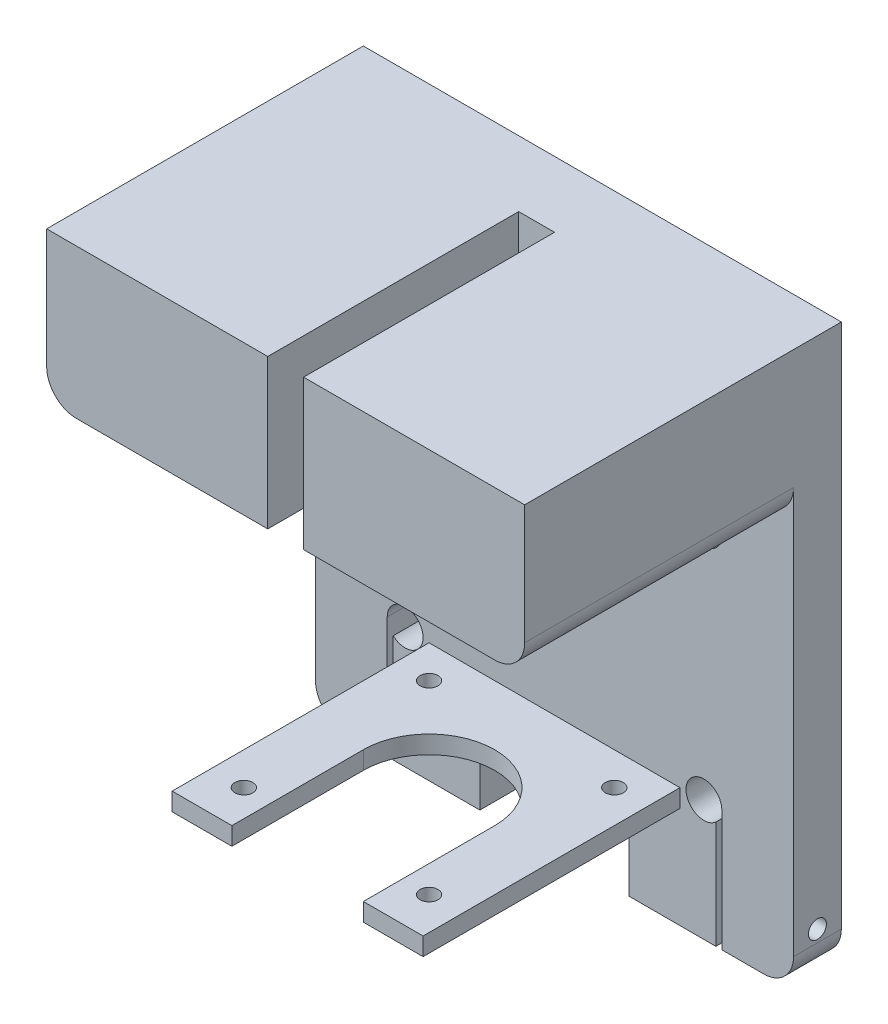
from build123d import *

# Parameters (mm, degrees)
EXTRUDE_1_DEPTH          = 8
SKETCH_3_W               = 42
SKETCH_3_H               = 3
EXTRUDE_2_DEPTH          = 43
CUT_EXTRUDE_1_REACH      = 78
SKETCH_4_R               = 1.5
SKETCH_5_W               = 25
SKETCH_5_H               = 17
CUT_EXTRUDE_2_DEPTH      = 9
SKETCH_7_R               = 3
CUT_EXTRUDE_3_DEPTH      = 9
FILLET_1_R               = 5
CUT_EXTRUDE_4_DEPTH      = 9
SKETCH_9_R               = 1.5
CUT_EXTRUDE_5_DEPTH      = 1
CUT_EXTRUDE_5_DEPTH_BACK = 81
SKETCH_12_W              = 80
SKETCH_12_H              = 25
EXTRUDE_4_DEPTH          = 45
SKETCH_13_W              = 6
SKETCH_13_H              = 25
CUT_EXTRUDE_6_DEPTH      = 42
FILLET_3_R               = 5
FILLET_4_R               = 5


with BuildPart() as part:
    # 草图1 → 凸台-拉伸1 (new body)
    with BuildSketch(Plane.XY):
        Polygon((-40, -42.5), (40, -42.5), (40, 42.5), (40, 50.5), (-40, 50.5), (-40, 42.5), align=None)
    extrude(amount=EXTRUDE_1_DEPTH)

    # 草图3 → 凸台-拉伸2 (add)
    with BuildSketch(Plane.XY.offset(8)):
        with Locations((0, -24)):
            Rectangle(SKETCH_3_W, SKETCH_3_H)
    extrude(amount=EXTRUDE_2_DEPTH)

    # 草图4 → 切除-拉伸1 (cut, up to next)
    with BuildSketch(Plane.XZ.offset(25.5), mode=Mode.PRIVATE) as cut_extrude_1_sk1:
        with Locations((-15.5, 44.5)):
            Circle(SKETCH_4_R)
    cut_extrude_1_tool1 = extrude(cut_extrude_1_sk1.sketch, amount=-CUT_EXTRUDE_1_REACH, mode=Mode.PRIVATE) & part.part
    add(cut_extrude_1_tool1.solids().sort_by_distance((-15.5, -25.5, 44.5))[0], mode=Mode.SUBTRACT)
    # 草图4 → 切除-拉伸1 (cut, up to next)
    with BuildSketch(Plane.XZ.offset(25.5), mode=Mode.PRIVATE) as cut_extrude_1_sk2:
        with Locations((15.5, 44.5)):
            Circle(SKETCH_4_R)
    cut_extrude_1_tool2 = extrude(cut_extrude_1_sk2.sketch, amount=-CUT_EXTRUDE_1_REACH, mode=Mode.PRIVATE) & part.part
    add(cut_extrude_1_tool2.solids().sort_by_distance((15.5, -25.5, 44.5))[0], mode=Mode.SUBTRACT)
    # 草图4 → 切除-拉伸1 (cut, up to next)
    with BuildSketch(Plane.XZ.offset(25.5), mode=Mode.PRIVATE) as cut_extrude_1_sk3:
        with Locations((15.5, 13.5)):
            Circle(SKETCH_4_R)
    cut_extrude_1_tool3 = extrude(cut_extrude_1_sk3.sketch, amount=-CUT_EXTRUDE_1_REACH, mode=Mode.PRIVATE) & part.part
    add(cut_extrude_1_tool3.solids().sort_by_distance((15.5, -25.5, 13.5))[0], mode=Mode.SUBTRACT)
    # 草图4 → 切除-拉伸1 (cut, up to next)
    with BuildSketch(Plane.XZ.offset(25.5), mode=Mode.PRIVATE) as cut_extrude_1_sk4:
        with Locations((-15.5, 13.5)):
            Circle(SKETCH_4_R)
    cut_extrude_1_tool4 = extrude(cut_extrude_1_sk4.sketch, amount=-CUT_EXTRUDE_1_REACH, mode=Mode.PRIVATE) & part.part
    add(cut_extrude_1_tool4.solids().sort_by_distance((-15.5, -25.5, 13.5))[0], mode=Mode.SUBTRACT)
    # 草图4 → 切除-拉伸1 (cut, up to next)
    with BuildSketch(Plane.XZ.offset(25.5), mode=Mode.PRIVATE) as cut_extrude_1_sk5:
        with BuildLine():
            Line((-11, 29), (-11, 51))
            Line((-11, 51), (11, 51))
            Line((11, 51), (11, 29))
            ThreePointArc((11, 29), (0, 18), (-11, 29))
        make_face()
    cut_extrude_1_tool5 = extrude(cut_extrude_1_sk5.sketch, amount=-CUT_EXTRUDE_1_REACH, mode=Mode.PRIVATE) & part.part
    add(cut_extrude_1_tool5.solids().sort_by_distance((0, -25.5, 35.581943))[0], mode=Mode.SUBTRACT)

    # 草图5 → 切除-拉伸2 (cut, through all)
    with BuildSketch(Plane.XY.offset(8)):
        with Locations((0, -34)):
            Rectangle(SKETCH_5_W, SKETCH_5_H)
    extrude(amount=-CUT_EXTRUDE_2_DEPTH, mode=Mode.SUBTRACT)

    # 草图7 → 切除-拉伸3 (cut, through all)
    with BuildSketch(Plane.XY.offset(8)):
        with Locations((-25, 17.5)):
            Circle(SKETCH_7_R)
        with Locations((25, 17.5)):
            Circle(SKETCH_7_R)
        with Locations((-25, -22.25)):
            Circle(SKETCH_7_R)
        with Locations((25, -22.25)):
            Circle(SKETCH_7_R)
    extrude(amount=-CUT_EXTRUDE_3_DEPTH, mode=Mode.SUBTRACT)

    # 圆角1
    fillet_1_edges = [part.edges().sort_by_distance(p)[0] for p in [
        (-40, -42.5, 4),
    ]]
    fillet(fillet_1_edges, radius=FILLET_1_R)

    # 草图8 → 切除-拉伸4 (cut, through all)
    with BuildSketch(Plane.XY.offset(8)):
        with BuildLine():
            Line((-28, -22.25), (-28, -42.5))
            Line((-28, -42.5), (-27, -42.5))
            Line((-27, -42.5), (-27, -24.486067977))
            ThreePointArc((-27, -24.486067977), (-27.738612788, -23.474744871), (-28, -22.25))
        make_face()
        with BuildLine():
            Line((28, -42.5), (27, -42.5))
            Line((27, -42.5), (27, -24.486067977))
            ThreePointArc((27, -24.486067977), (27.738612788, -23.474744871), (28, -22.25))
            Line((28, -22.25), (28, -42.5))
        make_face()
    extrude(amount=-CUT_EXTRUDE_4_DEPTH, mode=Mode.SUBTRACT)

    # 草图9 → 切除-拉伸5 (cut, two sides)
    with BuildSketch(Plane.ZY.offset(40)) as cut_extrude_5_sk:
        with Locations((4, -35.5)):
            Circle(SKETCH_9_R)
    extrude(amount=CUT_EXTRUDE_5_DEPTH, mode=Mode.SUBTRACT)
    extrude(cut_extrude_5_sk.sketch, amount=-CUT_EXTRUDE_5_DEPTH_BACK, mode=Mode.SUBTRACT)

    # 草图12 → 凸台-拉伸4 (add)
    with BuildSketch(Plane.XY.offset(8)):
        with Locations((0, 38)):
            Rectangle(SKETCH_12_W, SKETCH_12_H)
    extrude(amount=EXTRUDE_4_DEPTH)

    # 草图13 → 切除-拉伸6 (cut)
    with BuildSketch(Plane.XY.offset(53)):
        with Locations((0, 38)):
            Rectangle(SKETCH_13_W, SKETCH_13_H)
    extrude(amount=-CUT_EXTRUDE_6_DEPTH, mode=Mode.SUBTRACT)

    # 圆角3
    fillet_3_edges = [part.edges().sort_by_distance(p)[0] for p in [
        (-40, 25.5, 30.5),
        (40, 25.5, 30.5),
    ]]
    fillet(fillet_3_edges, radius=FILLET_3_R)

    # 圆角4
    fillet_4_edges = [part.edges().sort_by_distance(p)[0] for p in [
        (40, -42.5, 4),
    ]]
    fillet(fillet_4_edges, radius=FILLET_4_R)


solid = part.part
